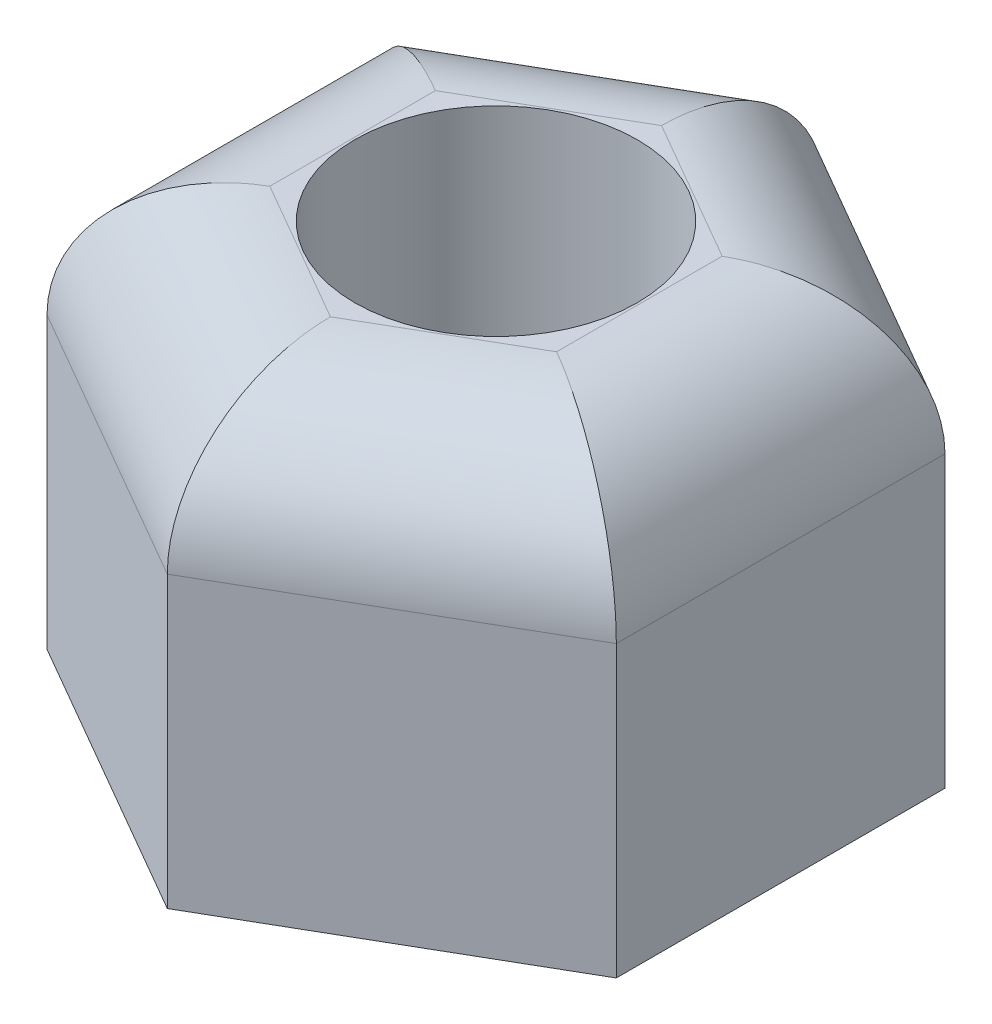
from build123d import *

# Parameters (mm, degrees)
SKETCH1_R           = 1
BOSS_EXTRUDE1_DEPTH = 3.05
FILLET1_R           = 1


with BuildPart() as part:
    # Sketch1 → Boss-Extrude1 (new body)
    with BuildSketch(Plane(origin=(0, 0, 0), x_dir=(1, 0, 0), z_dir=(0, 1, 0))):
        Polygon((2.015, 1.163360792), (0, 2.326721585), (-2.015, 1.163360792), (-2.015, -1.163360792), (0, -2.326721585), (2.015, -1.163360792), align=None)
        Circle(SKETCH1_R, mode=Mode.SUBTRACT)
    extrude(amount=BOSS_EXTRUDE1_DEPTH)

    # Fillet1
    fillet1_edges = [part.edges().sort_by_distance(p)[0] for p in [
        (-1.0075, 3.05, -1.745041189),
        (-2.015, 3.05, 0),
        (-1.0075, 3.05, 1.745041189),
        (1.0075, 3.05, 1.745041189),
        (2.015, 3.05, 0),
        (1.0075, 3.05, -1.745041189),
    ]]
    fillet(fillet1_edges, radius=FILLET1_R)


solid = part.part
